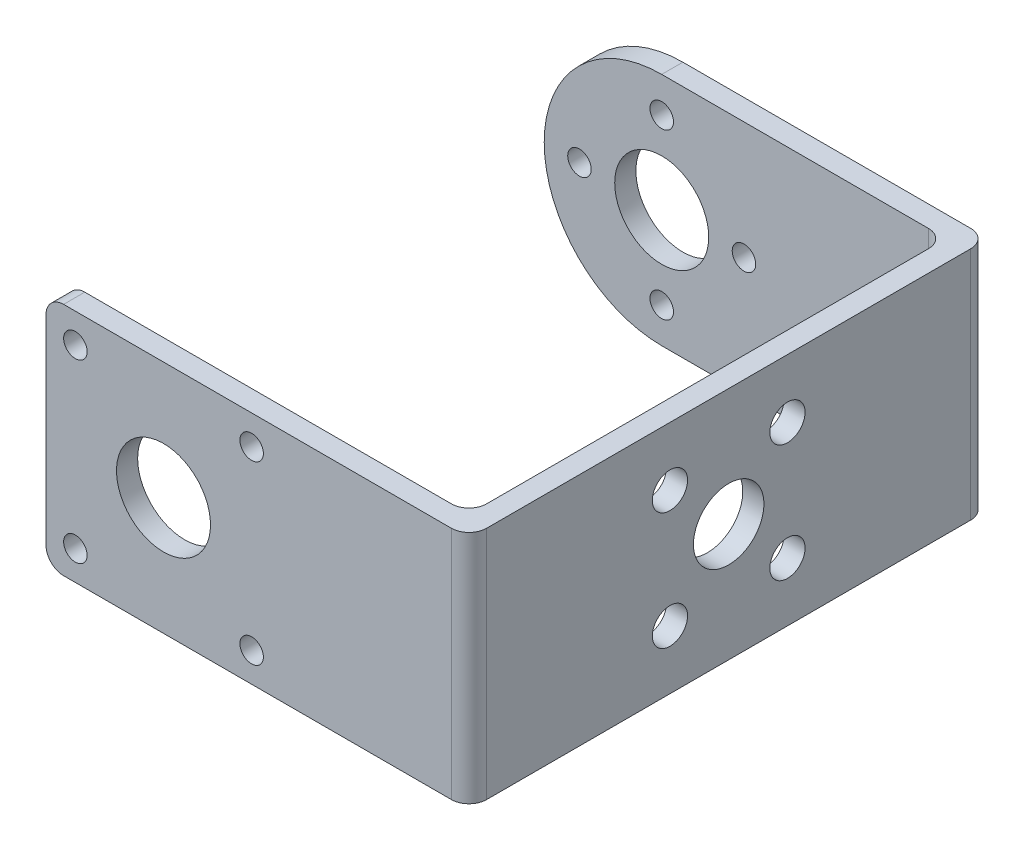
from build123d import *

# Parameters (mm, degrees)
BOSS_EXTRUDE1_DEPTH = 10
FILLET1_R           = 1.5
CUT_EXTRUDE1_DEPTH  = 2
SKETCH4_R           = 4
CUT_EXTRUDE3_DEPTH  = 45.2
SKETCH6_R           = 3
SKETCH6_R_2         = 1.5
CUT_EXTRUDE4_DEPTH  = 2
SKETCH7_R           = 1
CUT_EXTRUDE5_DEPTH  = 2
SKETCH8_R           = 1
CUT_EXTRUDE6_DEPTH  = 2


with BuildPart() as part:
    # Sketch1 → Boss-Extrude1 (new body, symmetric)
    with BuildSketch(Plane(origin=(0, 0, 0), x_dir=(1, 0, 0), z_dir=(0, 1, 0))):
        Polygon((-18, 20.3), (16.2, 20.3), (16.2, -20.3), (-18, -20.3), (-18, -22.1), (18, -22.1), (18, 22.1), (-18, 22.1), align=None)
    extrude(amount=BOSS_EXTRUDE1_DEPTH, both=True)

    # Fillet1
    fillet1_edges = [part.edges().sort_by_distance(p)[0] for p in [
        (18, 0, -22.1),
        (18, 0, 22.1),
        (16.2, 0, 20.3),
        (16.2, 0, -20.3),
        (-18, 10, 21.2),
        (-18, -10, 21.2),
    ]]
    fillet(fillet1_edges, radius=FILLET1_R)

    # Sketch2 → Cut-Extrude1 (cut)
    with BuildSketch(Plane(origin=(0, 0, -22.1), x_dir=(-1, 0, 0), z_dir=(0, 0, -1))):
        with BuildLine():
            Line((18, 10), (8, 10))
            ThreePointArc((8, 10), (15.071067812, 7.071067812), (18, 0))
            Line((18, 0), (18, 10))
        make_face()
        with BuildLine():
            Line((18, -10), (18, 0))
            ThreePointArc((18, 0), (15.071067812, -7.071067812), (8, -10))
            Line((8, -10), (18, -10))
        make_face()
    extrude(amount=-CUT_EXTRUDE1_DEPTH, mode=Mode.SUBTRACT)

    # Sketch4 → Cut-Extrude3 (cut, through all)
    with BuildSketch(Plane.XY.offset(22.1)):
        with Locations((-8, 0)):
            Circle(SKETCH4_R)
    extrude(amount=-CUT_EXTRUDE3_DEPTH, mode=Mode.SUBTRACT)

    # Sketch6 → Cut-Extrude4 (cut)
    with BuildSketch(Plane.ZY.offset(-16.2)):
        Circle(SKETCH6_R)
        with Locations((5, -5)):
            Circle(SKETCH6_R_2)
        with Locations((-5, -5)):
            Circle(SKETCH6_R_2)
        with Locations((-5, 5)):
            Circle(SKETCH6_R_2)
        with Locations((5, 5)):
            Circle(SKETCH6_R_2)
    extrude(amount=-CUT_EXTRUDE4_DEPTH, mode=Mode.SUBTRACT)

    # Sketch7 → Cut-Extrude5 (cut)
    with BuildSketch(Plane.XY.offset(22.1)):
        with Locations((-15.5, -7.5)):
            Circle(SKETCH7_R)
        with Locations((-15.5, 7.5)):
            Circle(SKETCH7_R)
        with Locations((-0.5, 7.5)):
            Circle(SKETCH7_R)
        with Locations((-0.5, -7.5)):
            Circle(SKETCH7_R)
    extrude(amount=-CUT_EXTRUDE5_DEPTH, mode=Mode.SUBTRACT)

    # Sketch8 → Cut-Extrude6 (cut)
    with BuildSketch(Plane(origin=(0, 0, -22.1), x_dir=(-1, 0, 0), z_dir=(0, 0, -1))):
        with Locations((8, -7)):
            Circle(SKETCH8_R)
        with Locations((15, 0)):
            Circle(SKETCH8_R)
        with Locations((8, 7)):
            Circle(SKETCH8_R)
        with Locations((1, 0)):
            Circle(SKETCH8_R)
    extrude(amount=-CUT_EXTRUDE6_DEPTH, mode=Mode.SUBTRACT)


solid = part.part
